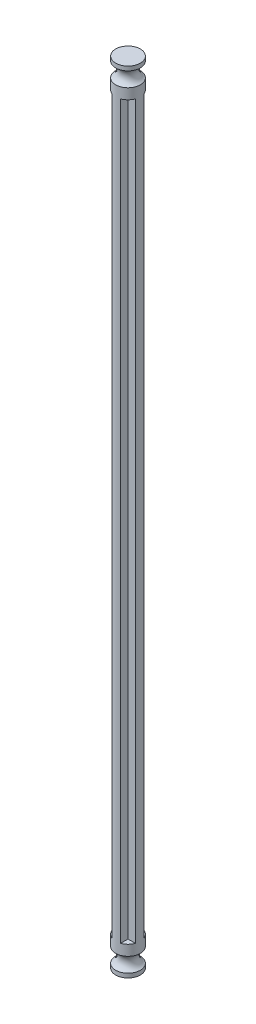
from build123d import *

# Parameters (mm, degrees)
EXTRUDE_2_DEPTH = 175.28


with BuildPart() as part:
    # 草图1 → 凸台-拉伸2 (new body)
    with BuildSketch(Plane(origin=(0, 0, 0), x_dir=(1, 0, 0), z_dir=(0, 1, 0))):
        with BuildLine():
            Line((1, 1), (1, 2.775338))
            ThreePointArc((1, 2.775338), (0, 2.95), (-1, 2.775338))
            Line((-1, 2.775338), (-1, 1))
            Line((-1, 1), (-2.775338, 1))
            ThreePointArc((-2.775338, 1), (-2.95, 0), (-2.775338, -1))
            Line((-2.775338, -1), (-1, -1))
            Line((-1, -1), (-1, -2.775338))
            ThreePointArc((-1, -2.775338), (0, -2.95), (1, -2.775338))
            Line((1, -2.775338), (1, -1))
            Line((1, -1), (2.775338, -1))
            ThreePointArc((2.775338, -1), (2.95, 0), (2.775338, 1))
            Line((2.775338, 1), (1, 1))
        make_face()
    extrude(amount=EXTRUDE_2_DEPTH)

    # 草图3 → 旋转3 (revolve)
    with BuildSketch(Plane(origin=(0, 0, 0), x_dir=(0, 0, -1), z_dir=(1, 0, 0))):
        with BuildLine():
            Line((0, 175.28), (0, 182.28))
            Line((0, 182.28), (2.95, 182.28))
            Line((2.95, 182.28), (2.95, 181.28))
            ThreePointArc((2.95, 181.28), (1.918246, 179.53), (2.95, 177.78))
            Line((2.95, 177.78), (2.95, 175.28))
            Line((2.95, 175.28), (0, 175.28))
        make_face()
        with BuildLine():
            Line((0, 0), (0, -7))
            Line((0, -7), (2.95, -7))
            Line((2.95, -7), (2.95, -6))
            ThreePointArc((2.95, -6), (1.918246, -4.25), (2.95, -2.5))
            Line((2.95, -2.5), (2.95, 0))
            Line((2.95, 0), (0, 0))
        make_face()
    revolve(axis=Axis((0, 0, 0), (0, -1, 0)))


solid = part.part
